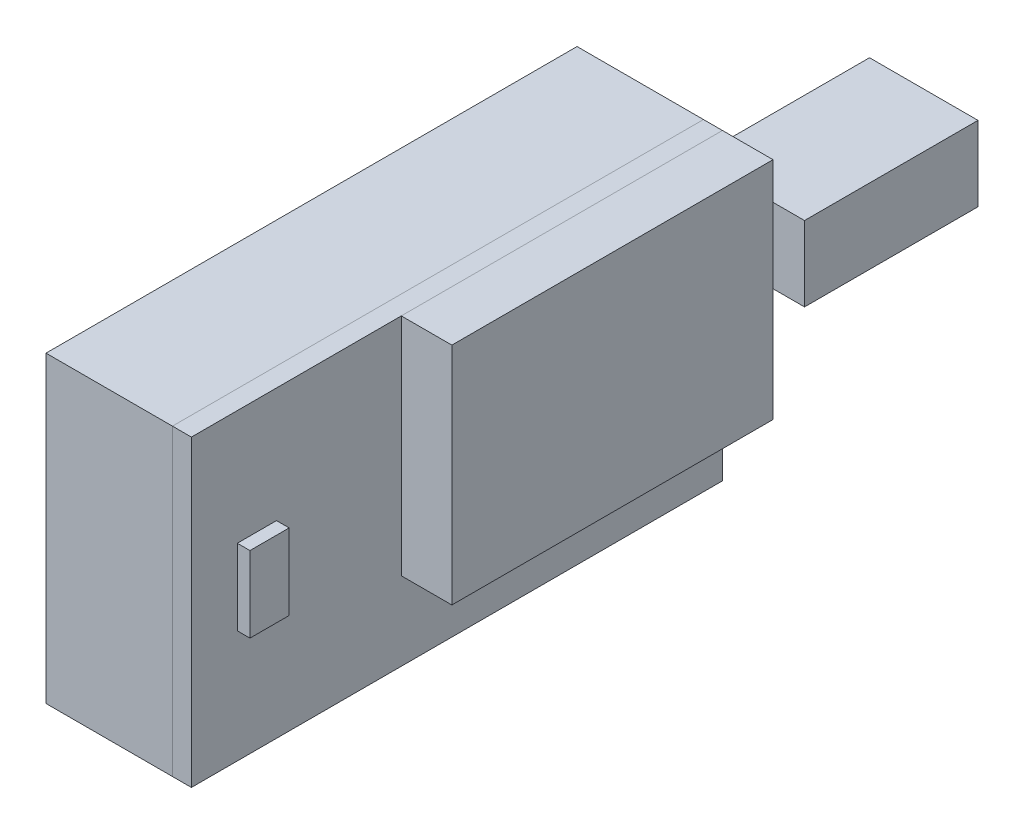
from build123d import *

# Parameters (mm, degrees)
SKETCH1_W        = 21
SKETCH1_H        = 12
BATTERY_DEPTH    = 5
SKETCH2_W        = 4.29
SKETCH2_H        = 2.96
DRIVER_DEPTH     = 6.86
SKETCH6_W        = 21
SKETCH6_H        = 12
PCB_BOARD_DEPTH  = 0.75
SKETCH7_W        = 12.7
SKETCH7_H        = 8.9
KLR_DEVICE_DEPTH = 2
SKETCH8_W        = 1.55
SKETCH8_H        = 3
ANTENNA_DEPTH    = 0.5


with BuildPart() as part:
    # Sketch1 → battery (new body)
    with BuildSketch(Plane(origin=(0, 0, 0), x_dir=(0, 0, -1), z_dir=(1, 0, 0))):
        with Locations((20.587318323, 21.170679999)):
            Rectangle(SKETCH1_W, SKETCH1_H)
    extrude(amount=BATTERY_DEPTH)


with BuildPart() as body_2:
    # Sketch2 → driver (new body)
    with BuildSketch(Plane(origin=(0, 0, -33.007318323), x_dir=(-1, 0, 0), z_dir=(0, 0, -1))):
        with Locations((-4.930759152, 22.310136325)):
            Rectangle(SKETCH2_W, SKETCH2_H)
    extrude(amount=DRIVER_DEPTH)


with BuildPart() as body_3:
    # Sketch6 → pcb board (new body)
    with BuildSketch(Plane(origin=(5, 0, 0), x_dir=(0, 0, -1), z_dir=(1, 0, 0))):
        with Locations((20.587318323, 21.170679999)):
            Rectangle(SKETCH6_W, SKETCH6_H)
    extrude(amount=PCB_BOARD_DEPTH)


with BuildPart() as body_4:
    # Sketch7 → KLR device (new body)
    with BuildSketch(Plane(origin=(5.75, 0, 0), x_dir=(0, 0, -1), z_dir=(1, 0, 0))):
        with Locations((24.737318323, 22.720679999)):
            Rectangle(SKETCH7_W, SKETCH7_H)
    extrude(amount=KLR_DEVICE_DEPTH)


with BuildPart() as body_5:
    # Sketch8 → antenna (new body)
    with BuildSketch(Plane(origin=(5.75, 0, 0), x_dir=(0, 0, -1), z_dir=(1, 0, 0))):
        with Locations((12.677856533, 21.127328905)):
            Rectangle(SKETCH8_W, SKETCH8_H)
    extrude(amount=ANTENNA_DEPTH)


solid = Compound([part.part, body_2.part, body_3.part, body_4.part, body_5.part])
